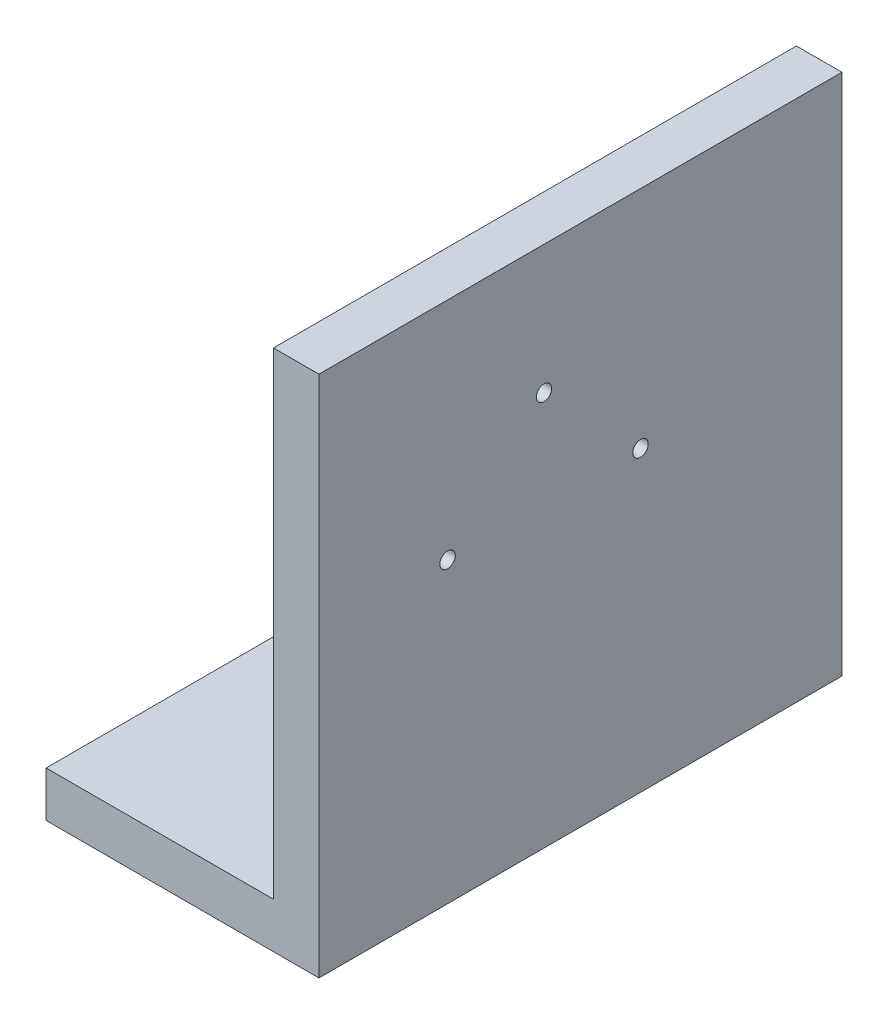
from build123d import *

# Parameters (mm, degrees)
SKETCH1_W           = 230
SKETCH1_H           = 230
BOSS_EXTRUDE1_DEPTH = 20
SKETCH2_R           = 3.4
CUT_EXTRUDE1_DEPTH  = 21
SKETCH3_W           = 230
SKETCH3_H           = 20
BOSS_EXTRUDE2_DEPTH = 100


with BuildPart() as part:
    # Sketch1 → Boss-Extrude1 (new body)
    with BuildSketch(Plane.ZY.offset(23545.4736246)):
        with Locations((40171.936259601, 5861.690204874)):
            Rectangle(SKETCH1_W, SKETCH1_H)
    extrude(amount=BOSS_EXTRUDE1_DEPTH)

    # Sketch2 → Cut-Extrude1 (cut, through all)
    with BuildSketch(Plane.ZY.offset(23565.4736246)):
        with Locations((40187.941310235, 5920.121662379)):
            Circle(SKETCH2_R)
        with Locations((40230.367717106, 5877.695255508)):
            Circle(SKETCH2_R)
        with Locations((40145.514903364, 5877.695255508)):
            Circle(SKETCH2_R)
    extrude(amount=-CUT_EXTRUDE1_DEPTH, mode=Mode.SUBTRACT)

    # Sketch3 → Boss-Extrude2 (add)
    with BuildSketch(Plane.ZY.offset(23565.4736246)):
        with Locations((40171.936259601, 5756.690204874)):
            Rectangle(SKETCH3_W, SKETCH3_H)
    extrude(amount=BOSS_EXTRUDE2_DEPTH)


solid = part.part
